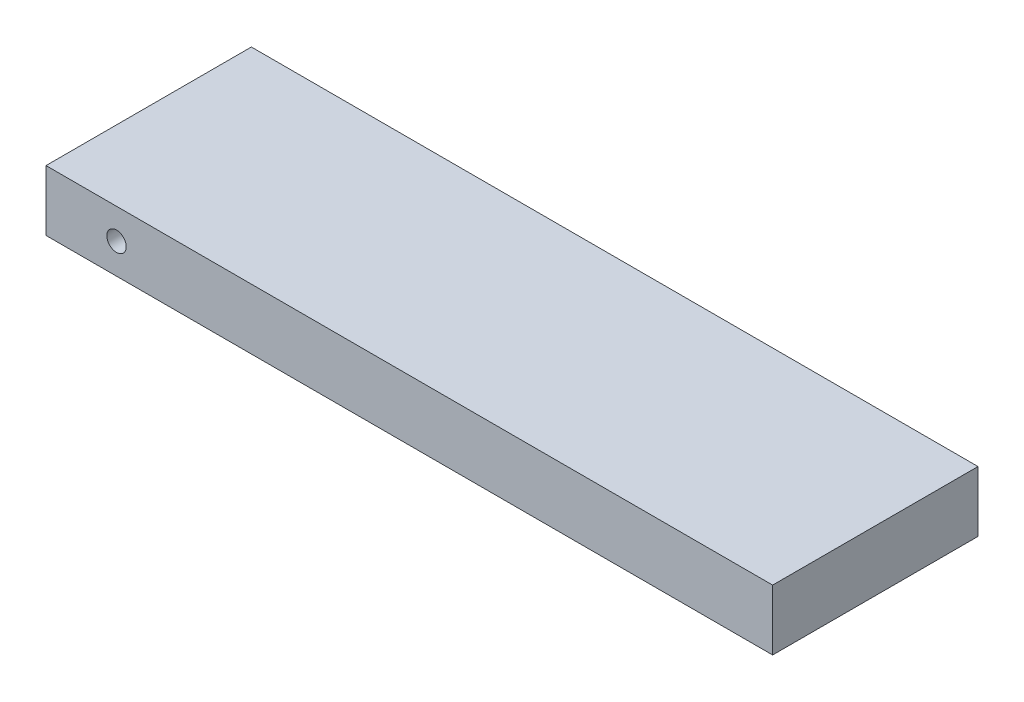
from build123d import *

# Parameters (mm, degrees)
SKETCH1_W                   = 60
SKETCH1_H                   = 16.957284299
BOSS_EXTRUDE1_DEPTH         = 5
TAP_DRILL_FOR_M2X0_4_TAP1_D = 1.6


with BuildPart() as part:
    # Sketch1 → Boss-Extrude1 (new body)
    with BuildSketch(Plane(origin=(0, 0, 0), x_dir=(1, 0, 0), z_dir=(0, 1, 0))):
        with Locations((-20.230276441, -316.427173265)):
            Rectangle(SKETCH1_W, SKETCH1_H)
    extrude(amount=BOSS_EXTRUDE1_DEPTH)

    # Tap Drill for M2x0.4 Tap1 (through all)
    with Locations(Plane.XY.offset(324.905815414)):
        with Locations((-44.406835203, 2.5)):
            Hole(TAP_DRILL_FOR_M2X0_4_TAP1_D / 2)


solid = part.part
